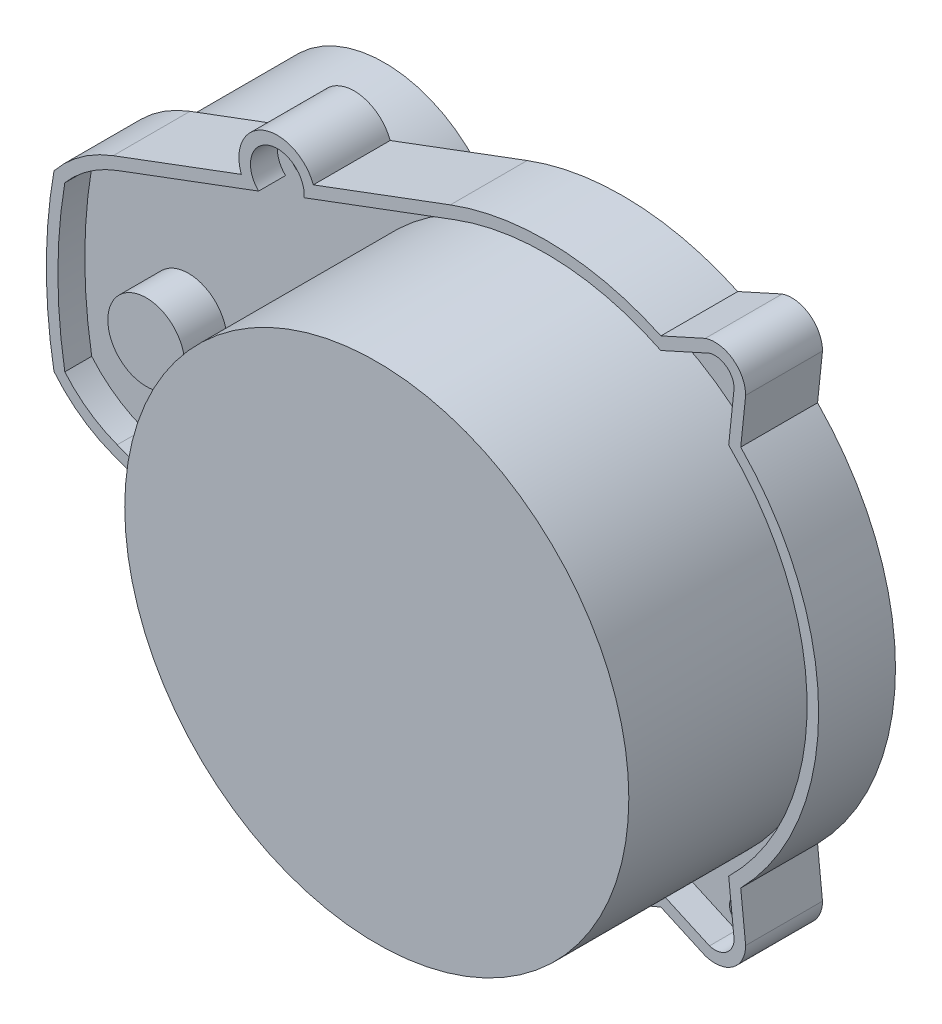
from build123d import *

# Parameters (mm, degrees)
ESQUISSE1_R             = 1.6
BOSS_EXTRU_1_DEPTH      = 10
ESQUISSE2_R             = 32.8
BOSS_EXTRU_2_DEPTH      = 22
ENL_V_MAT_EXTRU_1_DEPTH = 3.5
BOSS_EXTRU_3_REACH      = 12
ESQUISSE4_R             = 32.8
ESQUISSE5_R             = 16
BOSS_EXTRU_4_DEPTH      = 19
ESQUISSE8_R             = 5
BOSS_EXTRU_7_DEPTH      = 5.5


with BuildPart() as part:
    # Esquisse1 → Boss.-Extru.1 (new body)
    with BuildSketch(Plane.XY):
        with BuildLine():
            ThreePointArc((-56.3, -16.861494596), (-60.528670487, -14.599558136), (-64.01, -11.301322931))
            ThreePointArc((-64.01, -11.301322931), (-65, 0), (-64.01, 11.301322931))
            ThreePointArc((-64.01, 11.301322931), (-60.528670487, 14.599558136), (-56.3, 16.861494596))
            Line((-56.3, 16.861494596), (-39.624688626, 23.091930519))
            ThreePointArc((-39.624688626, 23.091930519), (-36.690940127, 29.525679018), (-30.257191628, 26.591930519))
            Line((-30.257191628, 26.591930519), (-12.425, 33.254614341))
            ThreePointArc((-12.425, 33.254614341), (1.381675102, 35.473102119), (14.973963383, 32.187426436))
            Line((14.973963383, 32.187426436), (20.756023105, 34.801647207))
            ThreePointArc((20.756023105, 34.801647207), (24.347774736, 34.238511045), (26, 31))
            Line((26, 31), (25.359978077, 24.841930519))
            ThreePointArc((25.359978077, 24.841930519), (35.5, 0), (25.359978077, -24.841930519))
            Line((25.359978077, -24.841930519), (26, -31))
            ThreePointArc((26, -31), (24.347774736, -34.238511045), (20.756023105, -34.801647207))
            Line((20.756023105, -34.801647207), (14.973963383, -32.187426436))
            ThreePointArc((14.973963383, -32.187426436), (1.381675102, -35.473102119), (-12.425, -33.254614341))
            Line((-12.425, -33.254614341), (-30.257191628, -26.591930519))
            ThreePointArc((-30.257191628, -26.591930519), (-36.690940127, -29.525679018), (-39.624688626, -23.091930519))
            Line((-39.624688626, -23.091930519), (-56.3, -16.861494596))
        make_face()
        with Locations((-35, -25)):
            Circle(ESQUISSE1_R, mode=Mode.SUBTRACT)
        with Locations((22, 31)):
            Circle(ESQUISSE1_R, mode=Mode.SUBTRACT)
        with Locations((-35, 25)):
            Circle(ESQUISSE1_R, mode=Mode.SUBTRACT)
        with Locations((22, -31)):
            Circle(ESQUISSE1_R, mode=Mode.SUBTRACT)
    extrude(amount=BOSS_EXTRU_1_DEPTH)

    # Esquisse2 → Boss.-Extru.2 (add)
    with BuildSketch(Plane.XY.offset(10)):
        Circle(ESQUISSE2_R)
    extrude(amount=BOSS_EXTRU_2_DEPTH)

    # Esquisse3 → Enlèv. mat.-Extru.1 (cut)
    with BuildSketch(Plane.XY.offset(10)):
        with BuildLine():
            Line((-55.775, -15.456370046), (-37.378202776, -22.330008789))
            ThreePointArc((-37.378202776, -22.330008789), (-36.165940127, -28.120554469), (-31.453677478, -24.543603151))
            Line((-31.453677478, -24.543603151), (-11.9, -31.849489792))
            ThreePointArc((-11.9, -31.849489792), (1.664031028, -33.959255009), (14.956816294, -30.533484019))
            Line((14.956816294, -30.533484019), (21.291141631, -33.397398551))
            ThreePointArc((21.291141631, -33.397398551), (23.468656713, -33.023128137), (24.499056843, -31.06866508))
            Line((24.499056843, -31.06866508), (23.79417774, -24.286562245))
            ThreePointArc((23.79417774, -24.286562245), (34, 0), (23.79417774, 24.286562245))
            Line((23.79417774, 24.286562245), (24.499056843, 31.06866508))
            ThreePointArc((24.499056843, 31.06866508), (23.468656713, 33.023128137), (21.291141631, 33.397398551))
            Line((21.291141631, 33.397398551), (14.956816294, 30.533484019))
            ThreePointArc((14.956816294, 30.533484019), (1.664031028, 33.959255009), (-11.9, 31.849489792))
            Line((-11.9, 31.849489792), (-31.453677478, 24.543603151))
            ThreePointArc((-31.453677478, 24.543603151), (-36.165940127, 28.120554469), (-37.378202776, 22.330008789))
            Line((-37.378202776, 22.330008789), (-55.775, 15.456370046))
            ThreePointArc((-55.775, 15.456370046), (-59.496201473, 13.493411636), (-62.6, 10.653168543))
            ThreePointArc((-62.6, 10.653168543), (-63.5, 0), (-62.6, -10.653168543))
            ThreePointArc((-62.6, -10.653168543), (-59.496201473, -13.493411636), (-55.775, -15.456370046))
        make_face()
    extrude(amount=-ENL_V_MAT_EXTRU_1_DEPTH, mode=Mode.SUBTRACT)

    # Esquisse4 → Boss.-Extru.3 (add, up to next)
    with BuildSketch(Plane(origin=(0, 0, 10), x_dir=(-1, 0, 0), z_dir=(0, 0, -1)), mode=Mode.PRIVATE) as boss_extru_3_sk1:
        Circle(ESQUISSE4_R)
    boss_extru_3_tool1 = extrude(boss_extru_3_sk1.sketch, amount=BOSS_EXTRU_3_REACH, mode=Mode.PRIVATE) - part.part
    add(boss_extru_3_tool1.solids().sort_by_distance((0, 0, 10))[0])

    # Esquisse5 → Boss.-Extru.4 (add)
    with BuildSketch(Plane(origin=(0, 0, 0), x_dir=(-1, 0, 0), z_dir=(0, 0, -1))):
        with Locations((50, 0)):
            Circle(ESQUISSE5_R)
    extrude(amount=BOSS_EXTRU_4_DEPTH)

    # Esquisse8 → Boss.-Extru.7 (add)
    with BuildSketch(Plane.XY.offset(6.5)):
        with Locations((-50, 0)):
            Circle(ESQUISSE8_R)
    extrude(amount=BOSS_EXTRU_7_DEPTH)


solid = part.part
